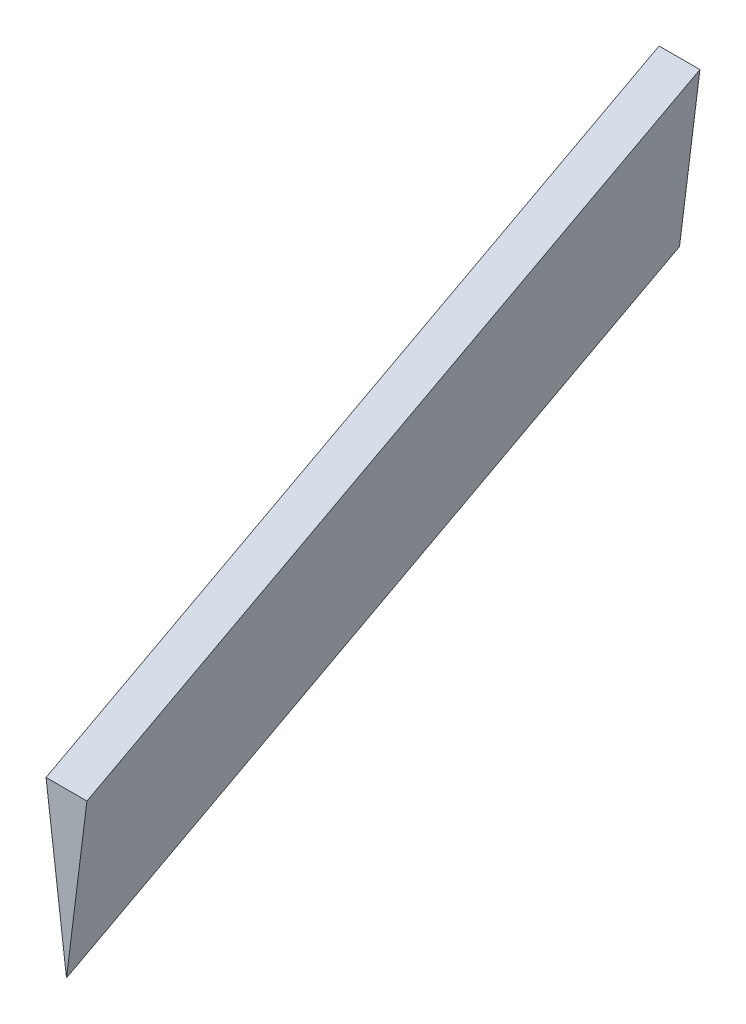
from build123d import *


with BuildPart() as part:
    # Sweep1: sweep along a path in Sketch1
    with BuildLine(Plane(origin=(0, 0, 0), x_dir=(0, 0, -1), z_dir=(1, 0, 0))) as sweep1_path:
        Line((0, 0), (95.25, 50.8))
    # Sketch2 → Sweep1 (sweep)
    with BuildSketch(Plane.XY):
        Polygon((-3.175, 0), (0, -25.4), (3.175, 0), align=None)
    sweep(path=sweep1_path.line)


solid = part.part
